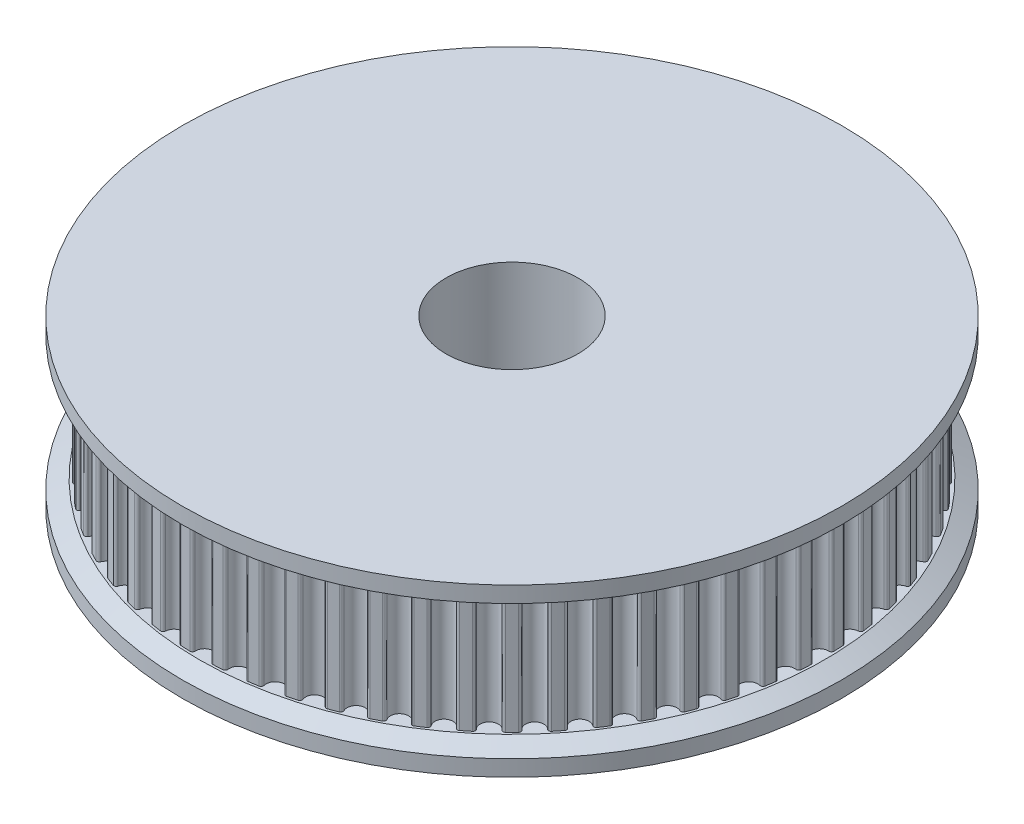
from build123d import *

# Parameters (mm, degrees)
SKETCH_1_R             = 10
SKETCH_1_R_2           = 4
EXTRUDE_1_DEPTH        = 7.45
SKETCH_2_R             = 4
EXTRUDE_2_DEPTH        = 7
SKETCH_3_R             = 20
SKETCH_3_R_2           = 4
EXTRUDE_3_DEPTH        = 1.55
CUT_EXTRUDE_1_REACH    = 22
SKETCH_4_R             = 1.5
CUT_EXTRUDE_2_REACH    = 22
SKETCH_5_R             = 1.5
SKETCH_7_R             = 20
SKETCH_7_R_2           = 4
EXTRUDE_4_DEPTH        = 1.55
CHAMFER_1_SIZE         = 1
CHAMFER_1_SIZE2        = 0.577350269
CHAMFER_1_PART_2_SIZE  = 1
CHAMFER_1_PART_2_SIZE2 = 0.577350269


with BuildPart() as part:
    # Эскиз1 → Бобышка-Вытянуть1 (new body)
    with BuildSketch(Plane(origin=(0, 0, 0), x_dir=(1, 0, 0), z_dir=(0, 1, 0))):
        Circle(SKETCH_1_R)
        Circle(SKETCH_1_R_2, mode=Mode.SUBTRACT)
    extrude(amount=EXTRUDE_1_DEPTH)

    # Эскиз2 → Бобышка-Вытянуть2 (add)
    with BuildSketch(Plane(origin=(0, 7.45, 0), x_dir=(1, 0, 0), z_dir=(0, 1, 0))):
        with BuildLine():
            ThreePointArc((1.268212169, 18.807289488), (0.986532775, 18.82416673), (0.704632299, 18.836825458))
            ThreePointArc((0.704632299, 18.836825458), (0.592145975, 18.792176877), (0.549234042, 18.67901666))
            ThreePointArc((0.549234042, 18.67901666), (0, 18.1), (-0.549234042, 18.67901666))
            ThreePointArc((-0.549234042, 18.67901666), (-0.592145975, 18.792176877), (-0.704632299, 18.836825458))
            ThreePointArc((-0.704632299, 18.836825458), (-0.986532775, 18.82416673), (-1.268212169, 18.807289488))
            ThreePointArc((-1.268212169, 18.807289488), (-1.375415233, 18.751127475), (-1.406263626, 18.634101643))
            ThreePointArc((-1.406263626, 18.634101643), (-1.891965185, 18.000846306), (-2.498714188, 18.519280462))
            ThreePointArc((-2.498714188, 18.519280462), (-2.553219508, 18.627335257), (-2.669756667, 18.659981226))
            ThreePointArc((-2.669756667, 18.659981226), (-2.948789666, 18.61792522), (-3.227161838, 18.571696919))
            ThreePointArc((-3.227161838, 18.571696919), (-3.327907104, 18.504636796), (-3.346353976, 18.385027509))
            ThreePointArc((-3.346353976, 18.385027509), (-3.763201604, 17.704471573), (-4.420817898, 18.156643152))
            ThreePointArc((-4.420817898, 18.156643152), (-4.486319434, 18.258408654), (-4.605630623, 18.278694334))
            ThreePointArc((-4.605630623, 18.278694334), (-4.878739, 18.207701826), (-5.150754047, 18.132628953))
            ThreePointArc((-5.150754047, 18.132628953), (-5.243937728, 18.055405444), (-5.249780971, 17.934523166))
            ThreePointArc((-5.249780971, 17.934523166), (-5.593207598, 17.214122945), (-6.294486201, 17.59507786))
            ThreePointArc((-6.294486201, 17.59507786), (-6.370266305, 17.689439105), (-6.491044326, 17.697142243))
            ThreePointArc((-6.491044326, 17.697142243), (-6.755235849, 17.597991039), (-7.017913517, 17.494896109))
            ThreePointArc((-7.017913517, 17.494896109), (-7.102514673, 17.408355292), (-7.095690268, 17.287524434))
            ThreePointArc((-7.095690268, 17.287524434), (-7.36193324, 16.535172783), (-8.099190797, 16.840737213))
            ThreePointArc((-8.099190797, 16.840737213), (-8.184419205, 16.926660359), (-8.305340789, 16.921696558))
            ThreePointArc((-8.305340789, 16.921696558), (-8.55772092, 16.795472981), (-8.808183258, 16.665485522))
            ThreePointArc((-8.808183258, 16.665485522), (-8.883274981, 16.570575556), (-8.863857697, 16.451119967))
            ThreePointArc((-8.863857697, 16.451119967), (-9.05, 15.675059808), (-9.815158964, 15.901885924))
            ThreePointArc((-9.815158964, 15.901885924), (-9.908901896, 15.97842958), (-10.0286422, 15.960853224))
            ThreePointArc((-10.0286422, 15.960853224), (-10.26644581, 15.808940206), (-10.5019487, 15.653484389))
            ThreePointArc((-10.5019487, 15.653484389), (-10.56670827, 15.551245126), (-10.534910846, 15.434473587))
            ThreePointArc((-10.534910846, 15.434473587), (-10.638913066, 14.643207598), (-11.423590195, 14.788810246))
            ThreePointArc((-11.423590195, 14.788810246), (-11.524820584, 14.855135783), (-11.642067708, 14.825139442))
            ThreePointArc((-11.642067708, 14.825139442), (-11.862689371, 14.649201373), (-12.080652594, 14.469980405))
            ThreePointArc((-12.080652594, 14.469980405), (-12.134370491, 14.361532001), (-12.090541307, 14.248723884))
            ThreePointArc((-12.090541307, 14.248723884), (-12.111263975, 13.450921341), (-12.906862181, 13.513705268))
            ThreePointArc((-12.906862181, 13.513705268), (-13.014470926, 13.56908601), (-13.127940287, 13.52699833))
            ThreePointArc((-13.127940287, 13.52699833), (-13.328962825, 13.328962825), (-13.52699833, 13.127940287))
            ThreePointArc((-13.52699833, 13.127940287), (-13.56908601, 13.014470926), (-13.513705268, 12.906862181))
            ThreePointArc((-13.513705268, 12.906862181), (-13.450921341, 12.111263975), (-14.248723884, 12.090541307))
            ThreePointArc((-14.248723884, 12.090541307), (-14.361532001, 12.134370491), (-14.469980405, 12.080652594))
            ThreePointArc((-14.469980405, 12.080652594), (-14.649201373, 11.862689371), (-14.825139442, 11.642067708))
            ThreePointArc((-14.825139442, 11.642067708), (-14.855135783, 11.524820584), (-14.788810246, 11.423590195))
            ThreePointArc((-14.788810246, 11.423590195), (-14.643207598, 10.638913066), (-15.434473587, 10.534910846))
            ThreePointArc((-15.434473587, 10.534910846), (-15.551245126, 10.56670827), (-15.653484389, 10.5019487))
            ThreePointArc((-15.653484389, 10.5019487), (-15.808940206, 10.26644581), (-15.960853224, 10.0286422))
            ThreePointArc((-15.960853224, 10.0286422), (-15.97842958, 9.908901896), (-15.901885924, 9.815158964))
            ThreePointArc((-15.901885924, 9.815158964), (-15.675059808, 9.05), (-16.451119967, 8.863857697))
            ThreePointArc((-16.451119967, 8.863857697), (-16.570575556, 8.883274981), (-16.665485522, 8.808183258))
            ThreePointArc((-16.665485522, 8.808183258), (-16.795472981, 8.55772092), (-16.921696558, 8.305340789))
            ThreePointArc((-16.921696558, 8.305340789), (-16.926660359, 8.184419205), (-16.840737213, 8.099190797))
            ThreePointArc((-16.840737213, 8.099190797), (-16.535172783, 7.36193324), (-17.287524434, 7.095690268))
            ThreePointArc((-17.287524434, 7.095690268), (-17.408355292, 7.102514673), (-17.494896109, 7.017913517))
            ThreePointArc((-17.494896109, 7.017913517), (-17.597991039, 6.755235849), (-17.697142243, 6.491044326))
            ThreePointArc((-17.697142243, 6.491044326), (-17.689439105, 6.370266305), (-17.59507786, 6.294486201))
            ThreePointArc((-17.59507786, 6.294486201), (-17.214122945, 5.593207598), (-17.934523166, 5.249780971))
            ThreePointArc((-17.934523166, 5.249780971), (-18.055405444, 5.243937728), (-18.132628953, 5.150754047))
            ThreePointArc((-18.132628953, 5.150754047), (-18.207701826, 4.878739), (-18.278694334, 4.605630623))
            ThreePointArc((-18.278694334, 4.605630623), (-18.258408654, 4.486319434), (-18.156643152, 4.420817898))
            ThreePointArc((-18.156643152, 4.420817898), (-17.704471573, 3.763201604), (-18.385027509, 3.346353976))
            ThreePointArc((-18.385027509, 3.346353976), (-18.504636796, 3.327907104), (-18.571696919, 3.227161838))
            ThreePointArc((-18.571696919, 3.227161838), (-18.61792522, 2.948789666), (-18.659981226, 2.669756667))
            ThreePointArc((-18.659981226, 2.669756667), (-18.627335257, 2.553219508), (-18.519280462, 2.498714188))
            ThreePointArc((-18.519280462, 2.498714188), (-18.000846306, 1.891965185), (-18.634101643, 1.406263626))
            ThreePointArc((-18.634101643, 1.406263626), (-18.751127475, 1.375415233), (-18.807289488, 1.268212169))
            ThreePointArc((-18.807289488, 1.268212169), (-18.82416673, 0.986532775), (-18.836825458, 0.704632299))
            ThreePointArc((-18.836825458, 0.704632299), (-18.792176877, 0.592145975), (-18.67901666, 0.549234042))
            ThreePointArc((-18.67901666, 0.549234042), (-18.1, 0), (-18.67901666, -0.549234042))
            ThreePointArc((-18.67901666, -0.549234042), (-18.792176877, -0.592145975), (-18.836825458, -0.704632299))
            ThreePointArc((-18.836825458, -0.704632299), (-18.82416673, -0.986532775), (-18.807289488, -1.268212169))
            ThreePointArc((-18.807289488, -1.268212169), (-18.751127475, -1.375415233), (-18.634101643, -1.406263626))
            ThreePointArc((-18.634101643, -1.406263626), (-18.000846306, -1.891965185), (-18.519280462, -2.498714188))
            ThreePointArc((-18.519280462, -2.498714188), (-18.627335257, -2.553219508), (-18.659981226, -2.669756667))
            ThreePointArc((-18.659981226, -2.669756667), (-18.61792522, -2.948789666), (-18.571696919, -3.227161838))
            ThreePointArc((-18.571696919, -3.227161838), (-18.504636796, -3.327907104), (-18.385027509, -3.346353976))
            ThreePointArc((-18.385027509, -3.346353976), (-17.704471573, -3.763201604), (-18.156643152, -4.420817898))
            ThreePointArc((-18.156643152, -4.420817898), (-18.258408654, -4.486319434), (-18.278694334, -4.605630623))
            ThreePointArc((-18.278694334, -4.605630623), (-18.207701826, -4.878739), (-18.132628953, -5.150754047))
            ThreePointArc((-18.132628953, -5.150754047), (-18.055405444, -5.243937728), (-17.934523166, -5.249780971))
            ThreePointArc((-17.934523166, -5.249780971), (-17.214122945, -5.593207598), (-17.59507786, -6.294486201))
            ThreePointArc((-17.59507786, -6.294486201), (-17.689439105, -6.370266305), (-17.697142243, -6.491044326))
            ThreePointArc((-17.697142243, -6.491044326), (-17.597991039, -6.755235849), (-17.494896109, -7.017913517))
            ThreePointArc((-17.494896109, -7.017913517), (-17.408355292, -7.102514673), (-17.287524434, -7.095690268))
            ThreePointArc((-17.287524434, -7.095690268), (-16.535172783, -7.36193324), (-16.840737213, -8.099190797))
            ThreePointArc((-16.840737213, -8.099190797), (-16.926660359, -8.184419205), (-16.921696558, -8.305340789))
            ThreePointArc((-16.921696558, -8.305340789), (-16.795472981, -8.55772092), (-16.665485522, -8.808183258))
            ThreePointArc((-16.665485522, -8.808183258), (-16.570575556, -8.883274981), (-16.451119967, -8.863857697))
            ThreePointArc((-16.451119967, -8.863857697), (-15.675059808, -9.05), (-15.901885924, -9.815158964))
            ThreePointArc((-15.901885924, -9.815158964), (-15.97842958, -9.908901896), (-15.960853224, -10.0286422))
            ThreePointArc((-15.960853224, -10.0286422), (-15.808940206, -10.26644581), (-15.653484389, -10.5019487))
            ThreePointArc((-15.653484389, -10.5019487), (-15.551245126, -10.56670827), (-15.434473587, -10.534910846))
            ThreePointArc((-15.434473587, -10.534910846), (-14.643207598, -10.638913066), (-14.788810246, -11.423590195))
            ThreePointArc((-14.788810246, -11.423590195), (-14.855135783, -11.524820584), (-14.825139442, -11.642067708))
            ThreePointArc((-14.825139442, -11.642067708), (-14.649201373, -11.862689371), (-14.469980405, -12.080652594))
            ThreePointArc((-14.469980405, -12.080652594), (-14.361532001, -12.134370491), (-14.248723884, -12.090541307))
            ThreePointArc((-14.248723884, -12.090541307), (-13.450921341, -12.111263975), (-13.513705268, -12.906862181))
            ThreePointArc((-13.513705268, -12.906862181), (-13.56908601, -13.014470926), (-13.52699833, -13.127940287))
            ThreePointArc((-13.52699833, -13.127940287), (-13.328962825, -13.328962825), (-13.127940287, -13.52699833))
            ThreePointArc((-13.127940287, -13.52699833), (-13.014470926, -13.56908601), (-12.906862181, -13.513705268))
            ThreePointArc((-12.906862181, -13.513705268), (-12.111263975, -13.450921341), (-12.090541307, -14.248723884))
            ThreePointArc((-12.090541307, -14.248723884), (-12.134370491, -14.361532001), (-12.080652594, -14.469980405))
            ThreePointArc((-12.080652594, -14.469980405), (-11.862689371, -14.649201373), (-11.642067708, -14.825139442))
            ThreePointArc((-11.642067708, -14.825139442), (-11.524820584, -14.855135783), (-11.423590195, -14.788810246))
            ThreePointArc((-11.423590195, -14.788810246), (-10.638913066, -14.643207598), (-10.534910846, -15.434473587))
            ThreePointArc((-10.534910846, -15.434473587), (-10.56670827, -15.551245126), (-10.5019487, -15.653484389))
            ThreePointArc((-10.5019487, -15.653484389), (-10.26644581, -15.808940206), (-10.0286422, -15.960853224))
            ThreePointArc((-10.0286422, -15.960853224), (-9.908901896, -15.97842958), (-9.815158964, -15.901885924))
            ThreePointArc((-9.815158964, -15.901885924), (-9.05, -15.675059808), (-8.863857697, -16.451119967))
            ThreePointArc((-8.863857697, -16.451119967), (-8.883274981, -16.570575556), (-8.808183258, -16.665485522))
            ThreePointArc((-8.808183258, -16.665485522), (-8.55772092, -16.795472981), (-8.305340789, -16.921696558))
            ThreePointArc((-8.305340789, -16.921696558), (-8.184419205, -16.926660359), (-8.099190797, -16.840737213))
            ThreePointArc((-8.099190797, -16.840737213), (-7.36193324, -16.535172783), (-7.095690268, -17.287524434))
            ThreePointArc((-7.095690268, -17.287524434), (-7.102514673, -17.408355292), (-7.017913517, -17.494896109))
            ThreePointArc((-7.017913517, -17.494896109), (-6.755235849, -17.597991039), (-6.491044326, -17.697142243))
            ThreePointArc((-6.491044326, -17.697142243), (-6.370266305, -17.689439105), (-6.294486201, -17.59507786))
            ThreePointArc((-6.294486201, -17.59507786), (-5.593207598, -17.214122945), (-5.249780971, -17.934523166))
            ThreePointArc((-5.249780971, -17.934523166), (-5.243937728, -18.055405444), (-5.150754047, -18.132628953))
            ThreePointArc((-5.150754047, -18.132628953), (-4.878739, -18.207701826), (-4.605630623, -18.278694334))
            ThreePointArc((-4.605630623, -18.278694334), (-4.486319434, -18.258408654), (-4.420817898, -18.156643152))
            ThreePointArc((-4.420817898, -18.156643152), (-3.763201604, -17.704471573), (-3.346353976, -18.385027509))
            ThreePointArc((-3.346353976, -18.385027509), (-3.327907104, -18.504636796), (-3.227161838, -18.571696919))
            ThreePointArc((-3.227161838, -18.571696919), (-2.948789666, -18.61792522), (-2.669756667, -18.659981226))
            ThreePointArc((-2.669756667, -18.659981226), (-2.553219508, -18.627335257), (-2.498714188, -18.519280462))
            ThreePointArc((-2.498714188, -18.519280462), (-1.891965185, -18.000846306), (-1.406263626, -18.634101643))
            ThreePointArc((-1.406263626, -18.634101643), (-1.375415233, -18.751127475), (-1.268212169, -18.807289488))
            ThreePointArc((-1.268212169, -18.807289488), (-0.986532775, -18.82416673), (-0.704632299, -18.836825458))
            ThreePointArc((-0.704632299, -18.836825458), (-0.592145975, -18.792176877), (-0.549234042, -18.67901666))
            ThreePointArc((-0.549234042, -18.67901666), (0, -18.1), (0.549234042, -18.67901666))
            ThreePointArc((0.549234042, -18.67901666), (0.592145975, -18.792176877), (0.704632299, -18.836825458))
            ThreePointArc((0.704632299, -18.836825458), (0.986532775, -18.82416673), (1.268212169, -18.807289488))
            ThreePointArc((1.268212169, -18.807289488), (1.375415233, -18.751127475), (1.406263626, -18.634101643))
            ThreePointArc((1.406263626, -18.634101643), (1.891965185, -18.000846306), (2.498714188, -18.519280462))
            ThreePointArc((2.498714188, -18.519280462), (2.553219508, -18.627335257), (2.669756667, -18.659981226))
            ThreePointArc((2.669756667, -18.659981226), (2.948789666, -18.61792522), (3.227161838, -18.571696919))
            ThreePointArc((3.227161838, -18.571696919), (3.327907104, -18.504636796), (3.346353976, -18.385027509))
            ThreePointArc((3.346353976, -18.385027509), (3.763201604, -17.704471573), (4.420817898, -18.156643152))
            ThreePointArc((4.420817898, -18.156643152), (4.486319434, -18.258408654), (4.605630623, -18.278694334))
            ThreePointArc((4.605630623, -18.278694334), (4.878739, -18.207701826), (5.150754047, -18.132628953))
            ThreePointArc((5.150754047, -18.132628953), (5.243937728, -18.055405444), (5.249780971, -17.934523166))
            ThreePointArc((5.249780971, -17.934523166), (5.593207598, -17.214122945), (6.294486201, -17.59507786))
            ThreePointArc((6.294486201, -17.59507786), (6.370266305, -17.689439105), (6.491044326, -17.697142243))
            ThreePointArc((6.491044326, -17.697142243), (6.755235849, -17.597991039), (7.017913517, -17.494896109))
            ThreePointArc((7.017913517, -17.494896109), (7.102514673, -17.408355292), (7.095690268, -17.287524434))
            ThreePointArc((7.095690268, -17.287524434), (7.36193324, -16.535172783), (8.099190797, -16.840737213))
            ThreePointArc((8.099190797, -16.840737213), (8.184419205, -16.926660359), (8.305340789, -16.921696558))
            ThreePointArc((8.305340789, -16.921696558), (8.55772092, -16.795472981), (8.808183258, -16.665485522))
            ThreePointArc((8.808183258, -16.665485522), (8.883274981, -16.570575556), (8.863857697, -16.451119967))
            ThreePointArc((8.863857697, -16.451119967), (9.05, -15.675059808), (9.815158964, -15.901885924))
            ThreePointArc((9.815158964, -15.901885924), (9.908901896, -15.97842958), (10.0286422, -15.960853224))
            ThreePointArc((10.0286422, -15.960853224), (10.26644581, -15.808940206), (10.5019487, -15.653484389))
            ThreePointArc((10.5019487, -15.653484389), (10.56670827, -15.551245126), (10.534910846, -15.434473587))
            ThreePointArc((10.534910846, -15.434473587), (10.638913066, -14.643207598), (11.423590195, -14.788810246))
            ThreePointArc((11.423590195, -14.788810246), (11.524820584, -14.855135783), (11.642067708, -14.825139442))
            ThreePointArc((11.642067708, -14.825139442), (11.862689371, -14.649201373), (12.080652594, -14.469980405))
            ThreePointArc((12.080652594, -14.469980405), (12.134370491, -14.361532001), (12.090541307, -14.248723884))
            ThreePointArc((12.090541307, -14.248723884), (12.111263975, -13.450921341), (12.906862181, -13.513705268))
            ThreePointArc((12.906862181, -13.513705268), (13.014470926, -13.56908601), (13.127940287, -13.52699833))
            ThreePointArc((13.127940287, -13.52699833), (13.328962825, -13.328962825), (13.52699833, -13.127940287))
            ThreePointArc((13.52699833, -13.127940287), (13.56908601, -13.014470926), (13.513705268, -12.906862181))
            ThreePointArc((13.513705268, -12.906862181), (13.450921341, -12.111263975), (14.248723884, -12.090541307))
            ThreePointArc((14.248723884, -12.090541307), (14.361532001, -12.134370491), (14.469980405, -12.080652594))
            ThreePointArc((14.469980405, -12.080652594), (14.649201373, -11.862689371), (14.825139442, -11.642067708))
            ThreePointArc((14.825139442, -11.642067708), (14.855135783, -11.524820584), (14.788810246, -11.423590195))
            ThreePointArc((14.788810246, -11.423590195), (14.643207598, -10.638913066), (15.434473587, -10.534910846))
            ThreePointArc((15.434473587, -10.534910846), (15.551245126, -10.56670827), (15.653484389, -10.5019487))
            ThreePointArc((15.653484389, -10.5019487), (15.808940206, -10.26644581), (15.960853224, -10.0286422))
            ThreePointArc((15.960853224, -10.0286422), (15.97842958, -9.908901896), (15.901885924, -9.815158964))
            ThreePointArc((15.901885924, -9.815158964), (15.675059808, -9.05), (16.451119967, -8.863857697))
            ThreePointArc((16.451119967, -8.863857697), (16.570575556, -8.883274981), (16.665485522, -8.808183258))
            ThreePointArc((16.665485522, -8.808183258), (16.795472981, -8.55772092), (16.921696558, -8.305340789))
            ThreePointArc((16.921696558, -8.305340789), (16.926660359, -8.184419205), (16.840737213, -8.099190797))
            ThreePointArc((16.840737213, -8.099190797), (16.535172783, -7.36193324), (17.287524434, -7.095690268))
            ThreePointArc((17.287524434, -7.095690268), (17.408355292, -7.102514673), (17.494896109, -7.017913517))
            ThreePointArc((17.494896109, -7.017913517), (17.597991039, -6.755235849), (17.697142243, -6.491044326))
            ThreePointArc((17.697142243, -6.491044326), (17.689439105, -6.370266305), (17.59507786, -6.294486201))
            ThreePointArc((17.59507786, -6.294486201), (17.214122945, -5.593207598), (17.934523166, -5.249780971))
            ThreePointArc((17.934523166, -5.249780971), (18.055405444, -5.243937728), (18.132628953, -5.150754047))
            ThreePointArc((18.132628953, -5.150754047), (18.207701826, -4.878739), (18.278694334, -4.605630623))
            ThreePointArc((18.278694334, -4.605630623), (18.258408654, -4.486319434), (18.156643152, -4.420817898))
            ThreePointArc((18.156643152, -4.420817898), (17.704471573, -3.763201604), (18.385027509, -3.346353976))
            ThreePointArc((18.385027509, -3.346353976), (18.504636796, -3.327907104), (18.571696919, -3.227161838))
            ThreePointArc((18.571696919, -3.227161838), (18.61792522, -2.948789666), (18.659981226, -2.669756667))
            ThreePointArc((18.659981226, -2.669756667), (18.627335257, -2.553219508), (18.519280462, -2.498714188))
            ThreePointArc((18.519280462, -2.498714188), (18.000846306, -1.891965185), (18.634101643, -1.406263626))
            ThreePointArc((18.634101643, -1.406263626), (18.751127475, -1.375415233), (18.807289488, -1.268212169))
            ThreePointArc((18.807289488, -1.268212169), (18.82416673, -0.986532775), (18.836825458, -0.704632299))
            ThreePointArc((18.836825458, -0.704632299), (18.792176877, -0.592145975), (18.67901666, -0.549234042))
            ThreePointArc((18.67901666, -0.549234042), (18.1, 0), (18.67901666, 0.549234042))
            ThreePointArc((18.67901666, 0.549234042), (18.792176877, 0.592145975), (18.836825458, 0.704632299))
            ThreePointArc((18.836825458, 0.704632299), (18.82416673, 0.986532775), (18.807289488, 1.268212169))
            ThreePointArc((18.807289488, 1.268212169), (18.751127475, 1.375415233), (18.634101643, 1.406263626))
            ThreePointArc((18.634101643, 1.406263626), (18.000846306, 1.891965185), (18.519280462, 2.498714188))
            ThreePointArc((18.519280462, 2.498714188), (18.627335257, 2.553219508), (18.659981226, 2.669756667))
            ThreePointArc((18.659981226, 2.669756667), (18.61792522, 2.948789666), (18.571696919, 3.227161838))
            ThreePointArc((18.571696919, 3.227161838), (18.504636796, 3.327907104), (18.385027509, 3.346353976))
            ThreePointArc((18.385027509, 3.346353976), (17.704471573, 3.763201604), (18.156643152, 4.420817898))
            ThreePointArc((18.156643152, 4.420817898), (18.258408654, 4.486319434), (18.278694334, 4.605630623))
            ThreePointArc((18.278694334, 4.605630623), (18.207701826, 4.878739), (18.132628953, 5.150754047))
            ThreePointArc((18.132628953, 5.150754047), (18.055405444, 5.243937728), (17.934523166, 5.249780971))
            ThreePointArc((17.934523166, 5.249780971), (17.214122945, 5.593207598), (17.59507786, 6.294486201))
            ThreePointArc((17.59507786, 6.294486201), (17.689439105, 6.370266305), (17.697142243, 6.491044326))
            ThreePointArc((17.697142243, 6.491044326), (17.597991039, 6.755235849), (17.494896109, 7.017913517))
            ThreePointArc((17.494896109, 7.017913517), (17.408355292, 7.102514673), (17.287524434, 7.095690268))
            ThreePointArc((17.287524434, 7.095690268), (16.535172783, 7.36193324), (16.840737213, 8.099190797))
            ThreePointArc((16.840737213, 8.099190797), (16.926660359, 8.184419205), (16.921696558, 8.305340789))
            ThreePointArc((16.921696558, 8.305340789), (16.795472981, 8.55772092), (16.665485522, 8.808183258))
            ThreePointArc((16.665485522, 8.808183258), (16.570575556, 8.883274981), (16.451119967, 8.863857697))
            ThreePointArc((16.451119967, 8.863857697), (15.675059808, 9.05), (15.901885924, 9.815158964))
            ThreePointArc((15.901885924, 9.815158964), (15.97842958, 9.908901896), (15.960853224, 10.0286422))
            ThreePointArc((15.960853224, 10.0286422), (15.808940206, 10.26644581), (15.653484389, 10.5019487))
            ThreePointArc((15.653484389, 10.5019487), (15.551245126, 10.56670827), (15.434473587, 10.534910846))
            ThreePointArc((15.434473587, 10.534910846), (14.643207598, 10.638913066), (14.788810246, 11.423590195))
            ThreePointArc((14.788810246, 11.423590195), (14.855135783, 11.524820584), (14.825139442, 11.642067708))
            ThreePointArc((14.825139442, 11.642067708), (14.649201373, 11.862689371), (14.469980405, 12.080652594))
            ThreePointArc((14.469980405, 12.080652594), (14.361532001, 12.134370491), (14.248723884, 12.090541307))
            ThreePointArc((14.248723884, 12.090541307), (13.450921341, 12.111263975), (13.513705268, 12.906862181))
            ThreePointArc((13.513705268, 12.906862181), (13.56908601, 13.014470926), (13.52699833, 13.127940287))
            ThreePointArc((13.52699833, 13.127940287), (13.328962825, 13.328962825), (13.127940287, 13.52699833))
            ThreePointArc((13.127940287, 13.52699833), (13.014470926, 13.56908601), (12.906862181, 13.513705268))
            ThreePointArc((12.906862181, 13.513705268), (12.111263975, 13.450921341), (12.090541307, 14.248723884))
            ThreePointArc((12.090541307, 14.248723884), (12.134370491, 14.361532001), (12.080652594, 14.469980405))
            ThreePointArc((12.080652594, 14.469980405), (11.862689371, 14.649201373), (11.642067708, 14.825139442))
            ThreePointArc((11.642067708, 14.825139442), (11.524820584, 14.855135783), (11.423590195, 14.788810246))
            ThreePointArc((11.423590195, 14.788810246), (10.638913066, 14.643207598), (10.534910846, 15.434473587))
            ThreePointArc((10.534910846, 15.434473587), (10.56670827, 15.551245126), (10.5019487, 15.653484389))
            ThreePointArc((10.5019487, 15.653484389), (10.26644581, 15.808940206), (10.0286422, 15.960853224))
            ThreePointArc((10.0286422, 15.960853224), (9.908901896, 15.97842958), (9.815158964, 15.901885924))
            ThreePointArc((9.815158964, 15.901885924), (9.05, 15.675059808), (8.863857697, 16.451119967))
            ThreePointArc((8.863857697, 16.451119967), (8.883274981, 16.570575556), (8.808183258, 16.665485522))
            ThreePointArc((8.808183258, 16.665485522), (8.55772092, 16.795472981), (8.305340789, 16.921696558))
            ThreePointArc((8.305340789, 16.921696558), (8.184419205, 16.926660359), (8.099190797, 16.840737213))
            ThreePointArc((8.099190797, 16.840737213), (7.36193324, 16.535172783), (7.095690268, 17.287524434))
            ThreePointArc((7.095690268, 17.287524434), (7.102514673, 17.408355292), (7.017913517, 17.494896109))
            ThreePointArc((7.017913517, 17.494896109), (6.755235849, 17.597991039), (6.491044326, 17.697142243))
            ThreePointArc((6.491044326, 17.697142243), (6.370266305, 17.689439105), (6.294486201, 17.59507786))
            ThreePointArc((6.294486201, 17.59507786), (5.593207598, 17.214122945), (5.249780971, 17.934523166))
            ThreePointArc((5.249780971, 17.934523166), (5.243937728, 18.055405444), (5.150754047, 18.132628953))
            ThreePointArc((5.150754047, 18.132628953), (4.878739, 18.207701826), (4.605630623, 18.278694334))
            ThreePointArc((4.605630623, 18.278694334), (4.486319434, 18.258408654), (4.420817898, 18.156643152))
            ThreePointArc((4.420817898, 18.156643152), (3.763201604, 17.704471573), (3.346353976, 18.385027509))
            ThreePointArc((3.346353976, 18.385027509), (3.327907104, 18.504636796), (3.227161838, 18.571696919))
            ThreePointArc((3.227161838, 18.571696919), (2.948789666, 18.61792522), (2.669756667, 18.659981226))
            ThreePointArc((2.669756667, 18.659981226), (2.553219508, 18.627335257), (2.498714188, 18.519280462))
            ThreePointArc((2.498714188, 18.519280462), (1.891965185, 18.000846306), (1.406263626, 18.634101643))
            ThreePointArc((1.406263626, 18.634101643), (1.375415233, 18.751127475), (1.268212169, 18.807289488))
        make_face()
        Circle(SKETCH_2_R, mode=Mode.SUBTRACT)
    extrude(amount=EXTRUDE_2_DEPTH)

    # Эскиз3 → Бобышка-Вытянуть3 (add)
    with BuildSketch(Plane(origin=(0, 14.45, 0), x_dir=(1, 0, 0), z_dir=(0, 1, 0))):
        Circle(SKETCH_3_R)
        Circle(SKETCH_3_R_2, mode=Mode.SUBTRACT)
    extrude(amount=EXTRUDE_3_DEPTH)

    # Эскиз4 → Вырез-Вытянуть1 (cut, up to next)
    with BuildSketch(Plane.XY, mode=Mode.PRIVATE) as cut_extrude_1_sk1:
        with Locations((0, 3.725)):
            Circle(SKETCH_4_R)
    cut_extrude_1_tool1 = extrude(cut_extrude_1_sk1.sketch, amount=CUT_EXTRUDE_1_REACH, mode=Mode.PRIVATE) & part.part
    add(cut_extrude_1_tool1.solids().sort_by_distance((0, 3.725, 0))[0], mode=Mode.SUBTRACT)

    # Эскиз5 → Вырез-Вытянуть2 (cut, up to next)
    with BuildSketch(Plane(origin=(0, 0, 0), x_dir=(0, 0, -1), z_dir=(1, 0, 0)), mode=Mode.PRIVATE) as cut_extrude_2_sk1:
        with Locations((0, 3.725)):
            Circle(SKETCH_5_R)
    cut_extrude_2_tool1 = extrude(cut_extrude_2_sk1.sketch, amount=CUT_EXTRUDE_2_REACH, mode=Mode.PRIVATE) & part.part
    add(cut_extrude_2_tool1.solids().sort_by_distance((0, 3.725, 0))[0], mode=Mode.SUBTRACT)

    # Эскиз7 → Бобышка-Вытянуть4 (add)
    with BuildSketch(Plane.XZ.offset(-7.45)):
        Circle(SKETCH_7_R)
        Circle(SKETCH_7_R_2, mode=Mode.SUBTRACT)
    extrude(amount=EXTRUDE_4_DEPTH)

    # Фаска1
    chamfer_1_edges = [part.edges().sort_by_distance(p)[0] for p in [
        (-20, 14.45, 0),
    ]]
    chamfer_1_side = [part.faces().sort_by_distance(p)[0] for p in [
        (-19.434314575, 14.45, 0),
    ]]
    chamfer(chamfer_1_edges, length=CHAMFER_1_SIZE, length2=CHAMFER_1_SIZE2, reference=chamfer_1_side[0])

    # Фаска1 part 2
    chamfer_1_part_2_edges = [part.edges().sort_by_distance(p)[0] for p in [
        (-20, 7.45, 0),
    ]]
    chamfer_1_part_2_side = [part.faces().sort_by_distance(p)[0] for p in [
        (-19.434314575, 7.45, 0),
    ]]
    chamfer(chamfer_1_part_2_edges, length=CHAMFER_1_PART_2_SIZE, length2=CHAMFER_1_PART_2_SIZE2, reference=chamfer_1_part_2_side[0])


solid = part.part
